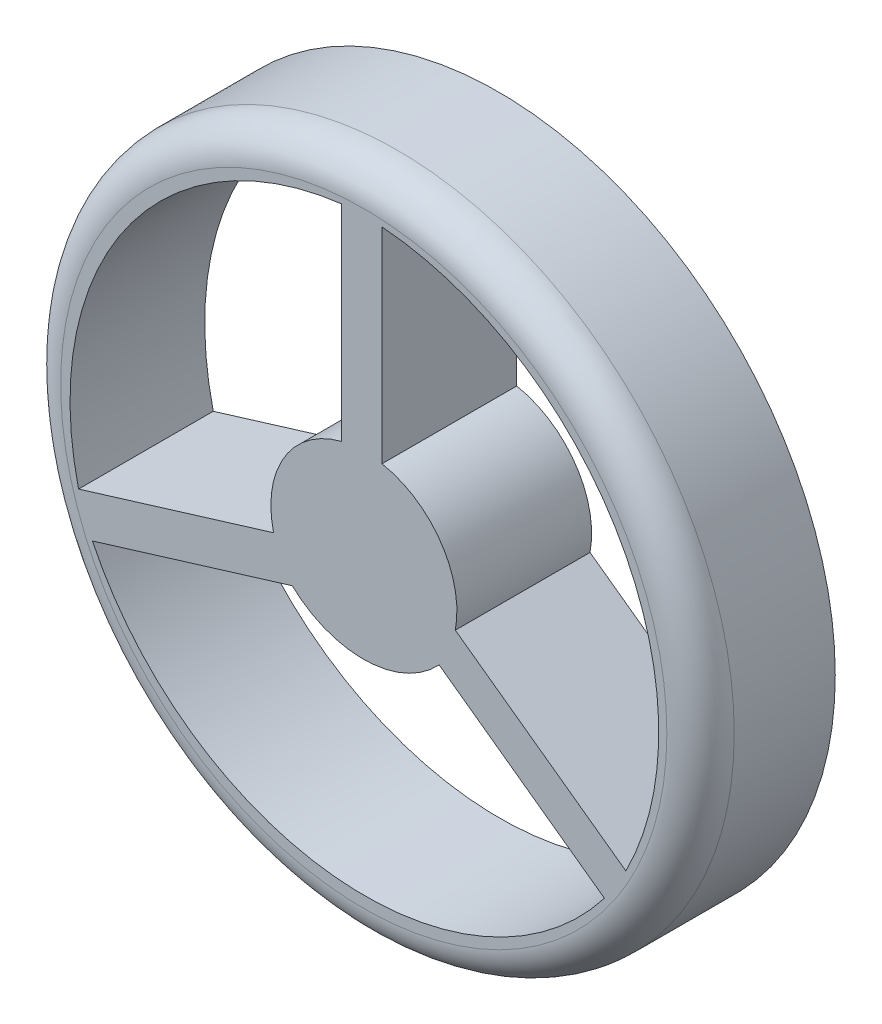
from build123d import *

# Parameters (mm, degrees)
SKETCH1_R           = 2.54
BOSS_EXTRUDE3_DEPTH = 1.016
FILLET1_R           = 0.254
CUT_EXTRUDE1_DEPTH  = 11.176


with BuildPart() as part:
    # Sketch1 → Boss-Extrude3 (new body)
    with BuildSketch(Plane.XY):
        Circle(SKETCH1_R)
    extrude(amount=BOSS_EXTRUDE3_DEPTH)

    # Fillet1
    fillet1_edges = [part.edges().sort_by_distance(p)[0] for p in [
        (-2.54, 0, 1.016),
    ]]
    fillet(fillet1_edges, radius=FILLET1_R)

    # Sketch3 → Cut-Extrude1 (cut)
    with BuildSketch(Plane.XY.offset(1.016)):
        with BuildLine():
            Line((-2.151072182, -0.621624482), (-0.679971736, -0.171586714))
            ThreePointArc((-0.679971736, -0.171586714), (-0.600265463, 0.360870926), (-0.167400209, 0.681014488))
            Line((-0.167400209, 0.681014488), (-0.167400209, 2.232824601))
            ThreePointArc((-0.167400209, 2.232824601), (-1.799371166, 1.250455709), (-2.151072182, -0.621624482))
        make_face()
        with BuildLine():
            Line((-2.046546593, -0.90839175), (-0.539954253, -0.447496333))
            ThreePointArc((-0.539954253, -0.447496333), (0.02185151, -0.658663896), (0.568426191, -0.410725247))
            Line((0.568426191, -0.410725247), (1.814888674, -1.311376236))
            ThreePointArc((1.814888674, -1.311376236), (-0.228235226, -2.186971416), (-2.046546593, -0.90839175))
        make_face()
        with BuildLine():
            Line((0.69044324, -0.122848261), (1.976507953, -1.052114462))
            ThreePointArc((1.976507953, -1.052114462), (1.936551374, 1.083523834), (0.137399791, 2.234871322))
            Line((0.137399791, 2.234871322), (0.137399791, 0.687695325))
            ThreePointArc((0.137399791, 0.687695325), (0.581790588, 0.39696258), (0.69044324, -0.122848261))
        make_face()
    extrude(amount=-CUT_EXTRUDE1_DEPTH, mode=Mode.SUBTRACT)


solid = part.part
